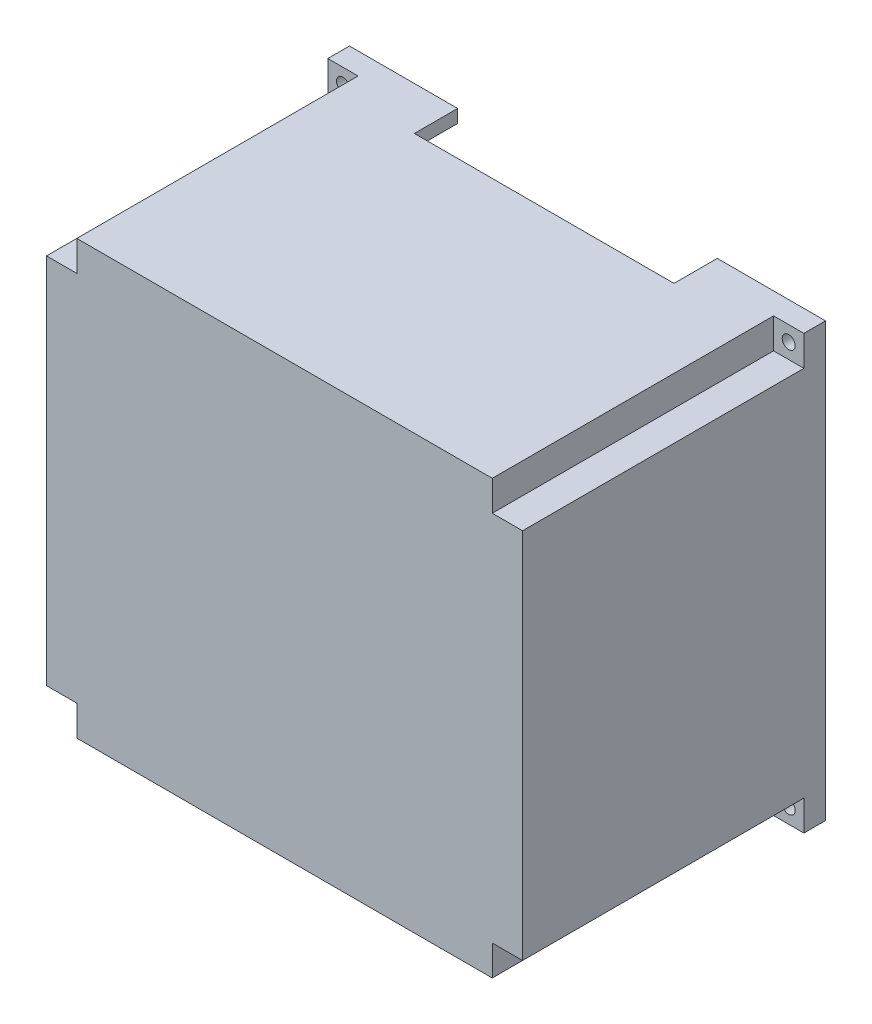
from build123d import *

# Parameters (mm, degrees)
SKETCH1_W           = 2794
SKETCH1_H           = 1778
BOSS_EXTRUDE1_DEPTH = 2540
SKETCH2_W           = 2641.6
SKETCH2_H           = 2387.6
CUT_EXTRUDE1_DEPTH  = 1701.8
SKETCH3_W           = 177.8
SKETCH3_H           = 177.8
BOSS_EXTRUDE2_DEPTH = 1701.8
SKETCH4_W           = 177.8
SKETCH4_H           = 177.8
CUT_EXTRUDE2_DEPTH  = 1651
SKETCH5_R           = 38.1
CUT_EXTRUDE5_DEPTH  = 1651
SKETCH6_W           = 1524
SKETCH6_H           = 254
CUT_EXTRUDE6_DEPTH  = 254


with BuildPart() as part:
    # Sketch1 → Boss-Extrude1 (new body)
    with BuildSketch(Plane(origin=(0, 0, 0), x_dir=(1, 0, 0), z_dir=(0, 1, 0))):
        with Locations((1397, 889)):
            Rectangle(SKETCH1_W, SKETCH1_H)
    extrude(amount=BOSS_EXTRUDE1_DEPTH)

    # Sketch2 → Cut-Extrude1 (cut)
    with BuildSketch(Plane(origin=(0, 0, -1778), x_dir=(-1, 0, 0), z_dir=(0, 0, -1))):
        with Locations((-1397, 1270)):
            Rectangle(SKETCH2_W, SKETCH2_H)
    extrude(amount=-CUT_EXTRUDE1_DEPTH, mode=Mode.SUBTRACT)

    # Sketch3 → Boss-Extrude2 (add)
    with BuildSketch(Plane(origin=(0, 0, -76.2), x_dir=(-1, 0, 0), z_dir=(0, 0, -1))):
        with Locations((-2628.9, 2374.9)):
            Rectangle(SKETCH3_W, SKETCH3_H)
        with Locations((-165.1, 2374.9)):
            Rectangle(SKETCH3_W, SKETCH3_H)
        with Locations((-2628.9, 165.1)):
            Rectangle(SKETCH3_W, SKETCH3_H)
        with Locations((-165.1, 165.1)):
            Rectangle(SKETCH3_W, SKETCH3_H)
    extrude(amount=BOSS_EXTRUDE2_DEPTH)

    # Sketch4 → Cut-Extrude2 (cut)
    with BuildSketch(Plane.XY):
        with Locations((88.9, 2451.1)):
            Rectangle(SKETCH4_W, SKETCH4_H)
        with Locations((2705.1, 2451.1)):
            Rectangle(SKETCH4_W, SKETCH4_H)
        with Locations((88.9, 88.9)):
            Rectangle(SKETCH4_W, SKETCH4_H)
        with Locations((2705.1, 88.9)):
            Rectangle(SKETCH4_W, SKETCH4_H)
    extrude(amount=-CUT_EXTRUDE2_DEPTH, mode=Mode.SUBTRACT)

    # Sketch5 → Cut-Extrude5 (cut)
    with BuildSketch(Plane(origin=(0, 0, -1778), x_dir=(-1, 0, 0), z_dir=(0, 0, -1))):
        with Locations((-2705.1, 2451.1)):
            Circle(SKETCH5_R)
        with Locations((-2705.1, 88.9)):
            Circle(SKETCH5_R)
        with Locations((-88.9, 2451.1)):
            Circle(SKETCH5_R)
        with Locations((-88.9, 88.9)):
            Circle(SKETCH5_R)
    extrude(amount=-CUT_EXTRUDE5_DEPTH, mode=Mode.SUBTRACT)

    # Sketch6 → Cut-Extrude6 (cut)
    with BuildSketch(Plane(origin=(0, 2540, 0), x_dir=(1, 0, 0), z_dir=(0, 1, 0))):
        with Locations((1397, 1651)):
            Rectangle(SKETCH6_W, SKETCH6_H)
    extrude(amount=-CUT_EXTRUDE6_DEPTH, mode=Mode.SUBTRACT)


solid = part.part
